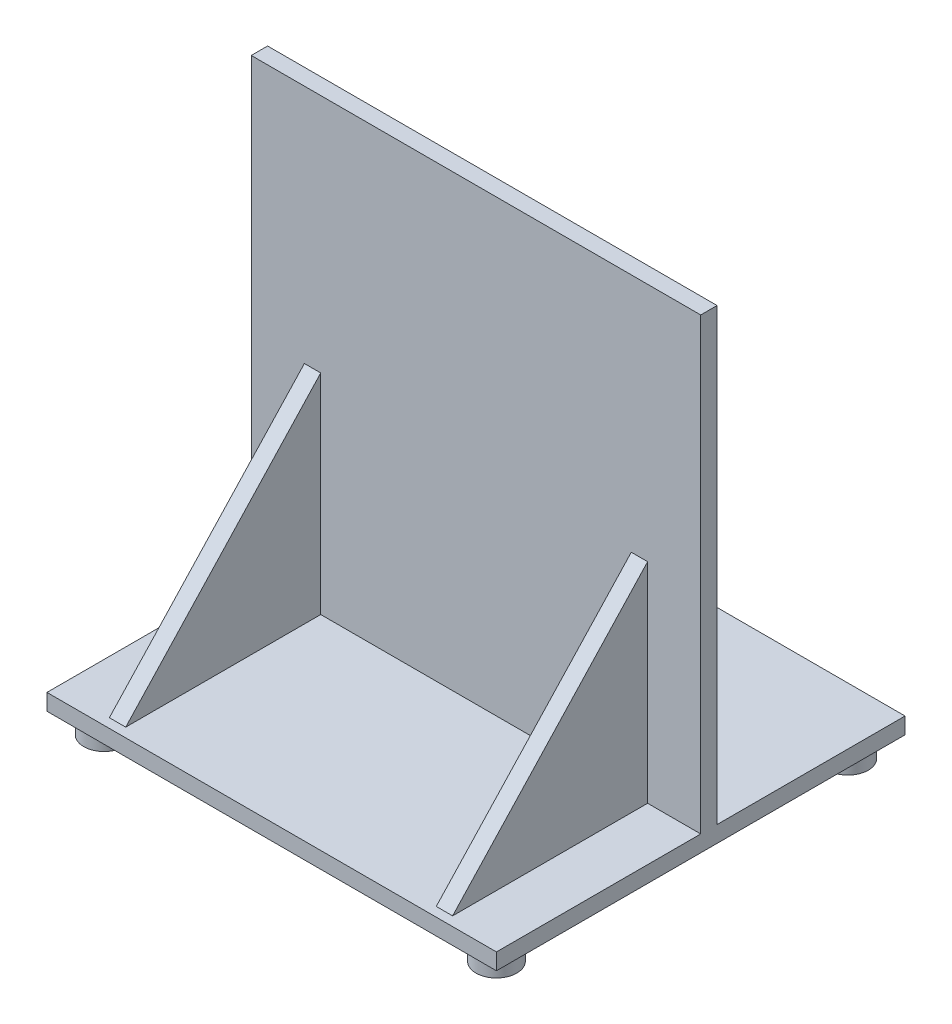
from build123d import *

# Parameters (mm, degrees)
ESQUISSE1_W             = 110
ESQUISSE1_H             = 110
BOSS_EXTRU_1_DEPTH      = 4
ESQUISSE2_W             = 110
ESQUISSE2_H             = 100
BOSS_EXTRU_2_DEPTH      = 4
ESQUISSE3_W             = 100
ESQUISSE3_H             = 100
ENL_V_MAT_EXTRU_1_DEPTH = 1
ESQUISSE6_R             = 5
BOSS_EXTRU_3_DEPTH      = 5
NERVURE1_REACH          = 139.095
ESQUISSE8_WALL_W        = 346.189200108
ESQUISSE8_WALL_H        = 4
NERVURE6_REACH          = 139.095
ESQUISSE9_WALL_W        = 346.189200108
ESQUISSE9_WALL_H        = 4


with BuildPart() as part:
    # Esquisse1 → Boss.-Extru.1 (new body)
    with BuildSketch(Plane.XY):
        with Locations((55, 27.788461538)):
            Rectangle(ESQUISSE1_W, ESQUISSE1_H)
    extrude(amount=BOSS_EXTRU_1_DEPTH)

    # Esquisse2 → Boss.-Extru.2 (add)
    with BuildSketch(Plane.XZ.offset(27.211538462)):
        with Locations((55, 4)):
            Rectangle(ESQUISSE2_W, ESQUISSE2_H)
    extrude(amount=BOSS_EXTRU_2_DEPTH)

    # Esquisse3 → Enlèv. mat.-Extru.1 (cut)
    with BuildSketch(Plane(origin=(0, 0, 0), x_dir=(-1, 0, 0), z_dir=(0, 0, -1))):
        with Locations((-55, 27.788461538)):
            Rectangle(ESQUISSE3_W, ESQUISSE3_H)
    extrude(amount=-ENL_V_MAT_EXTRU_1_DEPTH, mode=Mode.SUBTRACT)

    # Esquisse6 → Boss.-Extru.3 (add)
    with BuildSketch(Plane.XZ.offset(31.211538462)):
        with Locations(Location((7, 47, 0), (0, 0, 90))):
            Circle(ESQUISSE6_R)
        with Locations(Location((103, 47, 0), (0, 0, 90))):
            Circle(ESQUISSE6_R)
        with Locations(Location((7, -39, 0), (0, 0, 90))):
            Circle(ESQUISSE6_R)
        with Locations(Location((103, -39, 0), (0, 0, 90))):
            Circle(ESQUISSE6_R)
    extrude(amount=BOSS_EXTRU_3_DEPTH)

    # Esquisse8 wall → Nervure1 (add, up to next)
    with BuildSketch(Plane(origin=(15, -1.607688641, 27.863002208), x_dir=(0, 0.731538566297, -0.681800063083), z_dir=(0, 0.681800063083, 0.731538566297)), mode=Mode.PRIVATE) as nervure1_sk1:
        Rectangle(ESQUISSE8_WALL_W, ESQUISSE8_WALL_H)
    nervure1_tool1 = extrude(nervure1_sk1.sketch, amount=-NERVURE1_REACH, mode=Mode.PRIVATE) - part.part
    add(nervure1_tool1.solids().sort_by_distance((15, -1.607688641, 27.863002208))[0])

    # Esquisse9 wall → Nervure6 (add, up to next)
    with BuildSketch(Plane(origin=(95, -1.607688641, 27.863002208), x_dir=(0, -0.731538566297, 0.681800063083), z_dir=(0, -0.681800063083, -0.731538566297)), mode=Mode.PRIVATE) as nervure6_sk1:
        Rectangle(ESQUISSE9_WALL_W, ESQUISSE9_WALL_H)
    nervure6_tool1 = extrude(nervure6_sk1.sketch, amount=NERVURE6_REACH, mode=Mode.PRIVATE) - part.part
    add(nervure6_tool1.solids().sort_by_distance((95, -1.607688641, 27.863002208))[0])


solid = part.part
